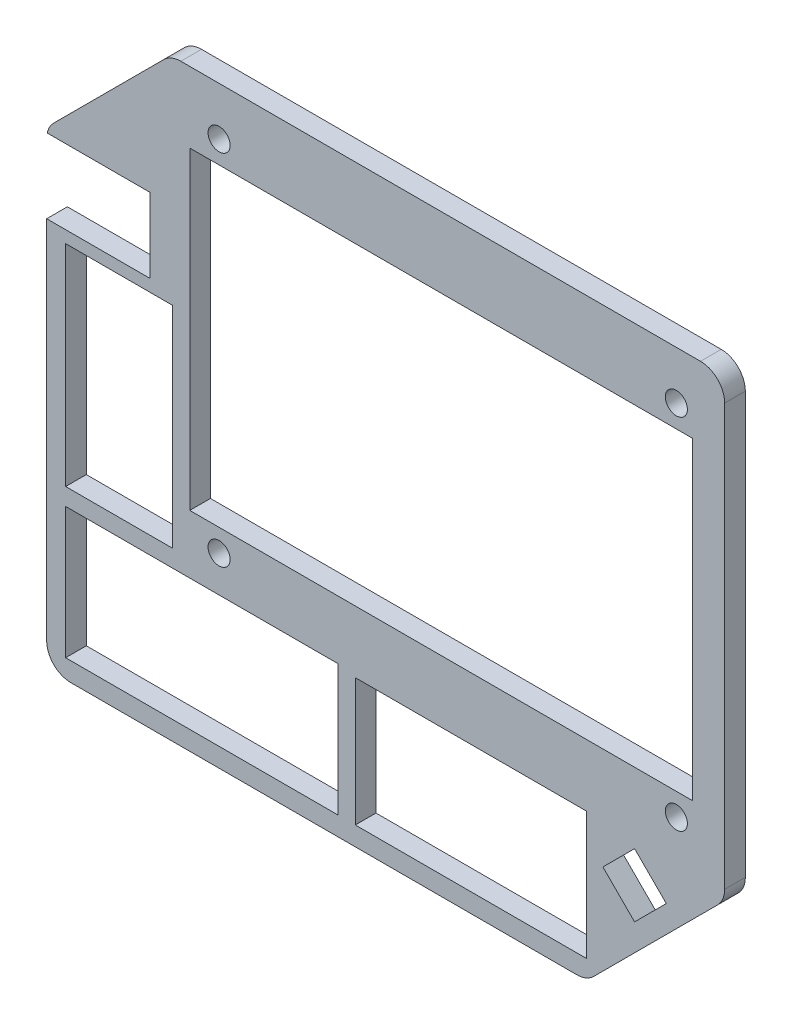
from build123d import *

# Parameters (mm, degrees)
BOSS_EXTRUDE1_DEPTH        = 3
FILLET1_R                  = 3.5
SKETCH2_W                  = 72.4
SKETCH2_H                  = 45
CUT_EXTRUDE1_DEPTH         = 104.986008674
SKETCH3_W                  = 33
SKETCH3_H                  = 18
SKETCH3_W_2                = 39
SKETCH3_H_2                = 18.5
SKETCH3_W_3                = 15
SKETCH3_H_3                = 30
CUT_EXTRUDE2_DEPTH         = 104.986008674
F_3_2_3_2_DIAMETER_HOLE1_D = 3.2
SKETCH9_W                  = 72.9
SKETCH9_H                  = 45.5
SKETCH9_W_2                = 33.5
SKETCH9_H_2                = 18.5
SKETCH9_W_3                = 39.5
SKETCH9_H_3                = 19
SKETCH9_W_4                = 15.5
SKETCH9_H_4                = 30.5
CUT_EXTRUDE3_DEPTH         = 104.986008674


with BuildPart() as part:
    # Sketch1 → Boss-Extrude1 (new body)
    with BuildSketch(Plane.XY):
        Polygon((60.3, -20), (80.3, 0), (80.3, 66), (0, 66), (-18, 48), (-18, -20), align=None)
    extrude(amount=BOSS_EXTRUDE1_DEPTH)

    # Fillet1
    fillet1_edges = [part.edges().sort_by_distance(p)[0] for p in [
        (80.3, 0, 1.5),
        (60.3, -20, 1.5),
        (-18, -20, 1.5),
        (-18, 48, 1.5),
        (80.3, 66, 1.5),
        (0, 66, 1.5),
    ]]
    fillet(fillet1_edges, radius=FILLET1_R)

    # Sketch2 → Cut-Extrude1 (cut, through all)
    with BuildSketch(Plane.XY.offset(3)):
        with Locations((39.2, 33)):
            Rectangle(SKETCH2_W, SKETCH2_H)
    extrude(amount=-CUT_EXTRUDE1_DEPTH, mode=Mode.SUBTRACT)

    # Sketch3 → Cut-Extrude2 (cut, through all)
    with BuildSketch(Plane.XY.offset(3)):
        with Locations((43.5, -8)):
            Rectangle(SKETCH3_W, SKETCH3_H)
        with Locations((4.5, -7.75)):
            Rectangle(SKETCH3_W_2, SKETCH3_H_2)
        with Locations((-7.5, 19.5)):
            Rectangle(SKETCH3_W_3, SKETCH3_H_3)
        with BuildLine():
            Line((-3, 47.3), (-17.918753974, 47.3))
            ThreePointArc((-17.918753974, 47.3), (-17.979629212, 46.927320889), (-18, 46.550252532))
            Line((-18, 46.550252532), (-18, 36.5))
            Line((-18, 36.5), (-3, 36.5))
            Line((-3, 36.5), (-3, 47.3))
        make_face()
        Polygon((63, -4.572077939), (67.242640687, -8.814718626), (71.485281374, -4.572077939), (67.242640687, -0.329437252), align=None)
    extrude(amount=-CUT_EXTRUDE2_DEPTH, mode=Mode.SUBTRACT)

    # Ø3.2 (3.2) Diameter Hole1 (through all)
    with Locations(Plane.XY.offset(3)):
        with Locations((7, 59), (73.3, 59), (73.3, 7), (7, 7)):
            Hole(F_3_2_3_2_DIAMETER_HOLE1_D / 2)

    # Sketch9 → Cut-Extrude3 (cut, through all)
    with BuildSketch(Plane.XY.offset(3)):
        with Locations((39.2, 33)):
            Rectangle(SKETCH9_W, SKETCH9_H)
        with Locations((43.5, -8)):
            Rectangle(SKETCH9_W_2, SKETCH9_H_2)
        Polygon((67.242640687, -9.168272016), (71.838834765, -4.572077939), (67.242640687, 0.024116139), (62.646446609, -4.572077939), align=None)
        with Locations((4.5, -7.75)):
            Rectangle(SKETCH9_W_3, SKETCH9_H_3)
        with Locations((-7.5, 19.5)):
            Rectangle(SKETCH9_W_4, SKETCH9_H_4)
    extrude(amount=-CUT_EXTRUDE3_DEPTH, mode=Mode.SUBTRACT)


solid = part.part
